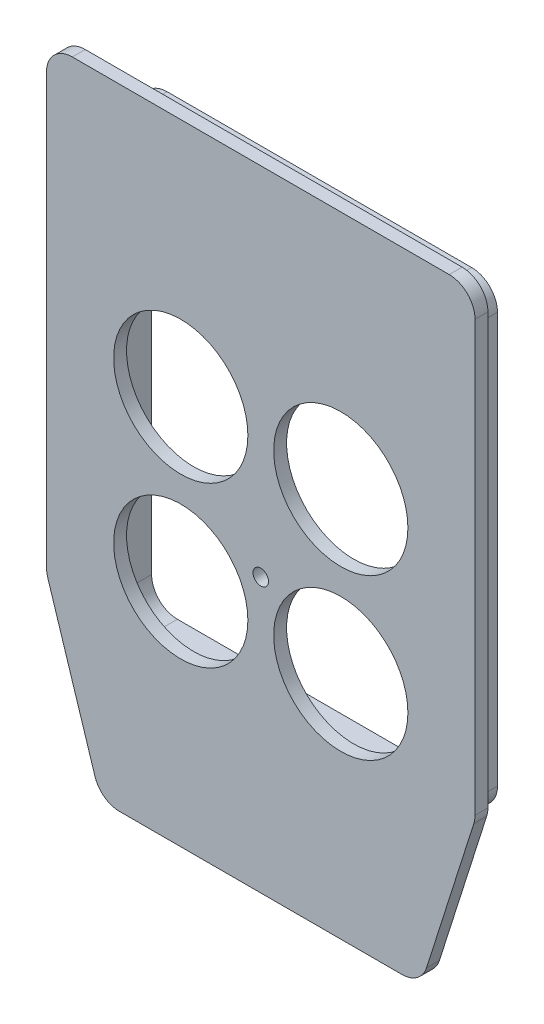
from build123d import *

# Parameters (mm, degrees)
SKETCH1_R           = 13
SKETCH1_R_2         = 1.5
BOSS_EXTRUDE1_DEPTH = 2.5
SKETCH2_W           = 69
SKETCH2_H           = 89.5
SKETCH2_W_2         = 65
SKETCH2_H_2         = 85.5
BOSS_EXTRUDE2_DEPTH = 8.85
FILLET1_R           = 5


with BuildPart() as part:
    # Sketch1 → Boss-Extrude1 (new body)
    with BuildSketch(Plane.XY):
        Polygon((0, 0), (10.5, -33), (72.5, -33), (83, 0), (83, 89), (0, 89), align=None)
        with Locations((26, 42.5)):
            Circle(SKETCH1_R, mode=Mode.SUBTRACT)
        with Locations((57, 42.5)):
            Circle(SKETCH1_R, mode=Mode.SUBTRACT)
        with Locations((26, 11.5)):
            Circle(SKETCH1_R, mode=Mode.SUBTRACT)
        with Locations((57, 11.5)):
            Circle(SKETCH1_R, mode=Mode.SUBTRACT)
        with Locations((41.5, 19.99)):
            Circle(SKETCH1_R_2, mode=Mode.SUBTRACT)
    extrude(amount=BOSS_EXTRUDE1_DEPTH)

    # Sketch2 → Boss-Extrude2 (add)
    with BuildSketch(Plane(origin=(0, 0, 0), x_dir=(-1, 0, 0), z_dir=(0, 0, -1))):
        with Locations((-41.5, 36.25)):
            Rectangle(SKETCH2_W, SKETCH2_H)
        with Locations((-41.5, 36.25)):
            Rectangle(SKETCH2_W_2, SKETCH2_H_2, mode=Mode.SUBTRACT)
    extrude(amount=BOSS_EXTRUDE2_DEPTH)

    # Fillet1
    fillet1_edges = [part.edges().sort_by_distance(p)[0] for p in [
        (0, 89, 1.25),
        (83, 89, 1.25),
        (83, 0, 1.25),
        (72.5, -33, 1.25),
        (10.5, -33, 1.25),
        (0, 0, 1.25),
        (74, -6.5, -4.425),
        (74, 79, -4.425),
        (9, 79, -4.425),
        (7, -8.5, -4.425),
        (7, 81, -4.425),
        (76, 81, -4.425),
        (76, -8.5, -4.425),
        (9, -6.5, -4.425),
    ]]
    fillet(fillet1_edges, radius=FILLET1_R)


solid = part.part
